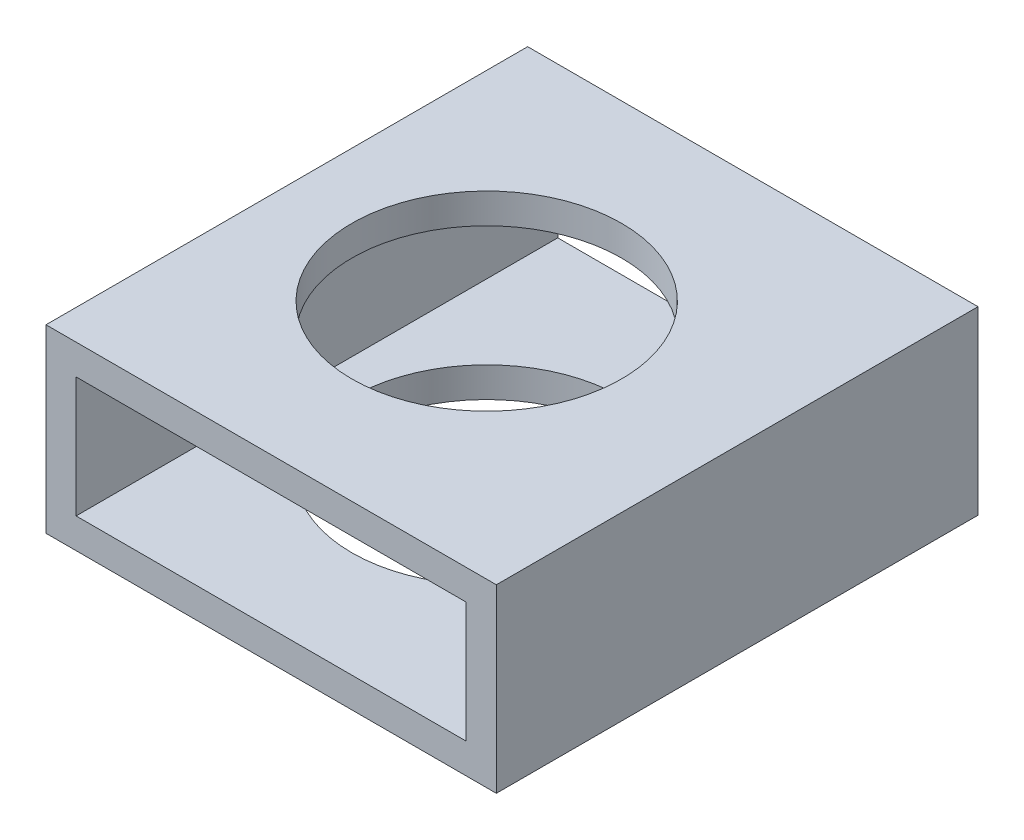
from build123d import *

# Parameters (mm, degrees)
SKETCH1_W           = 47.498
SKETCH1_H           = 19.05
BOSS_EXTRUDE1_DEPTH = 50.8
SKETCH2_W           = 41.148
SKETCH2_H           = 12.7
CUT_EXTRUDE1_DEPTH  = 51.8
SKETCH5_R           = 14.224
CUT_EXTRUDE2_DEPTH  = 20.05


with BuildPart() as part:
    # Sketch1 → Boss-Extrude1 (new body)
    with BuildSketch(Plane.XY):
        with Locations((-30.51329874, 11.587546426)):
            Rectangle(SKETCH1_W, SKETCH1_H)
    extrude(amount=BOSS_EXTRUDE1_DEPTH)

    # Sketch2 → Cut-Extrude1 (cut, through all)
    with BuildSketch(Plane(origin=(0, 0, 0), x_dir=(-1, 0, 0), z_dir=(0, 0, -1))):
        with Locations((30.51329874, 11.587546426)):
            Rectangle(SKETCH2_W, SKETCH2_H)
    extrude(amount=-CUT_EXTRUDE1_DEPTH, mode=Mode.SUBTRACT)

    # Sketch5 → Cut-Extrude2 (cut, through all)
    with BuildSketch(Plane(origin=(0, 21.112546426, 0), x_dir=(1, 0, 0), z_dir=(0, 1, 0))):
        with Locations((-33.18029874, -25.4)):
            Circle(SKETCH5_R)
    extrude(amount=-CUT_EXTRUDE2_DEPTH, mode=Mode.SUBTRACT)


solid = part.part
